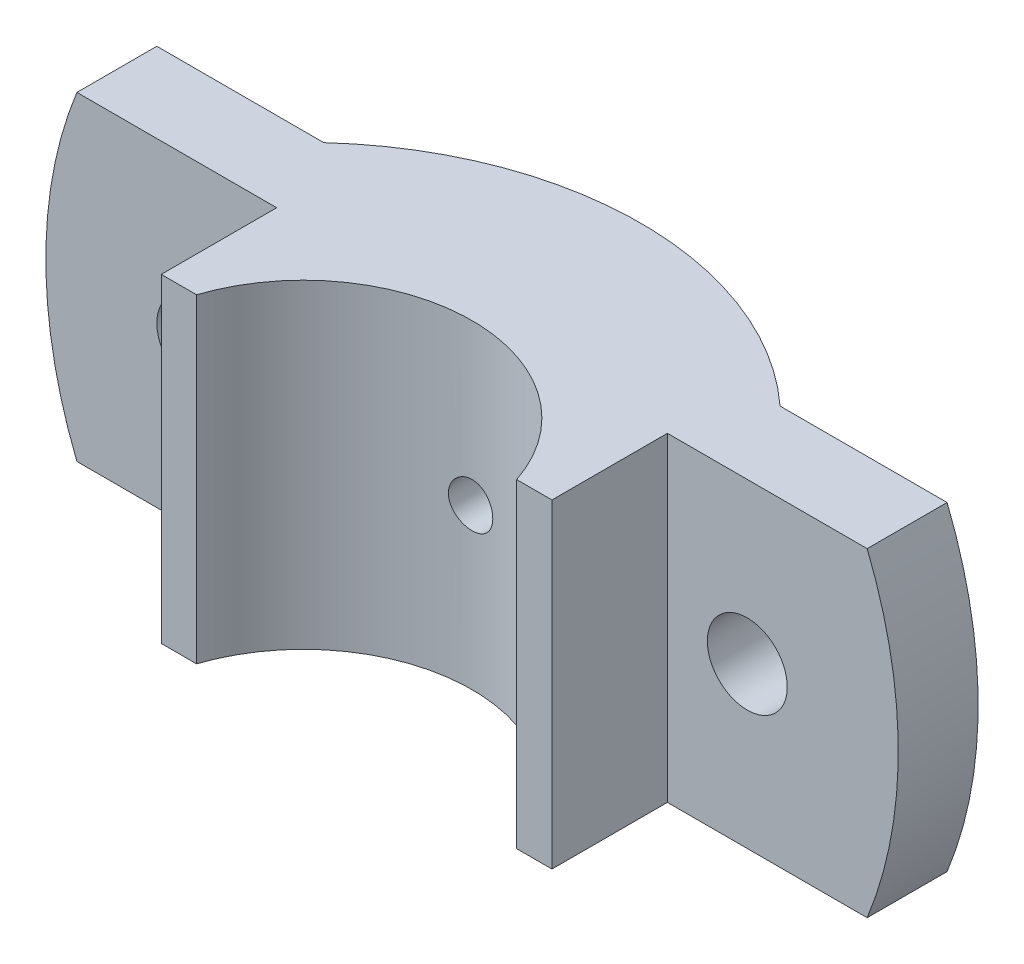
from build123d import *

# Parameters (mm, degrees)
BOSS_EXTRUDE1_DEPTH                     = 18
SKETCH2_R                               = 4.5
CUT_EXTRUDE1_DEPTH                      = 23
CUT_EXTRUDE9_DEPTH                      = 11
CUT_EXTRUDE10_DEPTH                     = 39.0000001
CBORE_FOR_M5_HEX_HEAD_BOLT1_D           = 5
CBORE_FOR_M5_HEX_HEAD_BOLT1_CBORE_D     = 6
CBORE_FOR_M5_HEX_HEAD_BOLT1_CBORE_DEPTH = 13


with BuildPart() as part:
    # Sketch1 → Boss-Extrude1 (new body, symmetric)
    with BuildSketch(Plane(origin=(0, 0, 0), x_dir=(1, 0, 0), z_dir=(0, 1, 0))):
        with BuildLine():
            Line((18.027756377, 6), (22, 6))
            Line((22, 6), (22, 19))
            Line((22, 19), (50, 19))
            Line((50, 19), (50, 28))
            Line((50, 28), (25.690465157, 28))
            ThreePointArc((25.690465157, 28), (0, 38), (-25.690465157, 28))
            Line((-25.690465157, 28), (-50, 28))
            Line((-50, 28), (-50, 19))
            Line((-50, 19), (-22, 19))
            Line((-22, 19), (-22, 6))
            Line((-22, 6), (-18.027756377, 6))
            ThreePointArc((-18.027756377, 6), (0, 19), (18.027756377, 6))
        make_face()
    extrude(amount=BOSS_EXTRUDE1_DEPTH, both=True)

    # Sketch2 → Cut-Extrude1 (cut, through all)
    with BuildSketch(Plane(origin=(0, 0, -28), x_dir=(-1, 0, 0), z_dir=(0, 0, -1))):
        with Locations((31, 0)):
            Circle(SKETCH2_R)
    cut_extrude1 = extrude(amount=-CUT_EXTRUDE1_DEPTH, mode=Mode.SUBTRACT)

    # Sketch3 → Cut-Extrude9 (cut, through all)
    with BuildSketch(Plane(origin=(0, 0, -28), x_dir=(-1, 0, 0), z_dir=(0, 0, -1))):
        with BuildLine():
            Line((25.690465157, 6.637683312), (25.690465157, -6.637683312))
            ThreePointArc((25.690465157, -6.637683312), (22.5, 0), (25.690465157, 6.637683312))
        make_face()
    cut_extrude9 = extrude(amount=CUT_EXTRUDE9_DEPTH, mode=Mode.SUBTRACT)

    # Sketch5 → Cut-Extrude10 (cut, through all)
    with BuildSketch(Plane.XY):
        with BuildLine():
            Line((-50, 18), (-50, -18))
            Line((-50, -18), (-44.497190923, -18))
            ThreePointArc((-44.497190923, -18), (-48, 0), (-44.497190923, 18))
            Line((-44.497190923, 18), (-50, 18))
        make_face()
    cut_extrude10 = extrude(amount=-CUT_EXTRUDE10_DEPTH, mode=Mode.SUBTRACT)

    # CBORE for M5 Hex Head Bolt1 (through all)
    with Locations(Plane(origin=(0, 0, -38), x_dir=(-1, 0, 0), z_dir=(0, 0, -1))):
        with Locations((0, 0)):
            CounterBoreHole(CBORE_FOR_M5_HEX_HEAD_BOLT1_D / 2, CBORE_FOR_M5_HEX_HEAD_BOLT1_CBORE_D / 2, CBORE_FOR_M5_HEX_HEAD_BOLT1_CBORE_DEPTH)

    # Mirror1: Cut-Extrude1, Cut-Extrude9, Cut-Extrude10 across plane
    add(cut_extrude1.mirror(Plane(origin=(0, 0, 0), x_dir=(0, 0, 1), z_dir=(1, 0, 0))), mode=Mode.SUBTRACT)
    add(cut_extrude9.mirror(Plane(origin=(0, 0, 0), x_dir=(0, 0, 1), z_dir=(1, 0, 0))), mode=Mode.SUBTRACT)
    add(cut_extrude10.mirror(Plane(origin=(0, 0, 0), x_dir=(0, 0, 1), z_dir=(1, 0, 0))), mode=Mode.SUBTRACT)


solid = part.part
